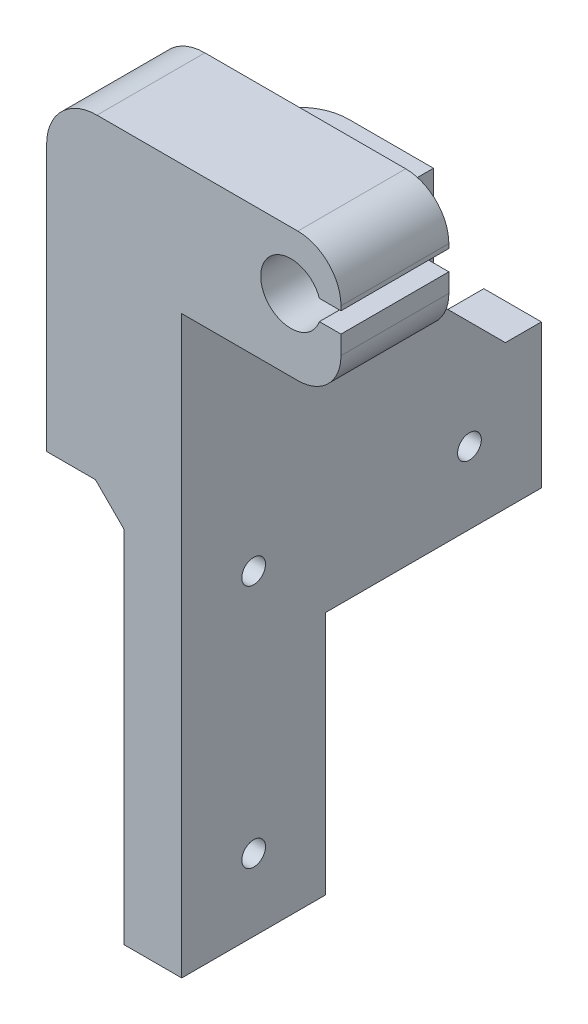
from build123d import *

# Parameters (mm, degrees)
EXTRUDE_1_DEPTH     = 15
SKETCH_4_W          = 18.78
SKETCH_4_H          = 26
EXTRUDE_4_DEPTH     = 20
SKETCH_5_W          = 8
SKETCH_5_H          = 54
EXTRUDE_5_DEPTH     = 5
SKETCH_6_R          = 4.2
CUT_EXTRUDE_1_DEPTH = 15
CHAMFER_1_SIZE      = 4
FILLET_3_R          = 7
FILLET_4_R          = 7
SKETCH_9_W          = 8
SKETCH_9_H          = 20
EXTRUDE_6_DEPTH     = 30
SKETCH_10_R         = 1.65
CUT_EXTRUDE_4_DEPTH = 30
CHAMFER_2_SIZE      = 10
SKETCH_11_W         = 3
SKETCH_11_H         = 6.600571545
SKETCH_11_H_2       = 8.600571545
EXTRUDE_7_DEPTH     = 15
FILLET_5_R          = 6
SKETCH_8_R          = 1.6
CUT_EXTRUDE_3_DEPTH = 93
FILLET_6_R          = 6


with BuildPart() as part:
    # 草图1 → 凸台-拉伸1 (new body)
    with BuildSketch(Plane.XY):
        Polygon((8, 26), (27.14, 26), (27.14, 44), (-10.78, 44), (-10.78, 0), (0, 0), (0, -54), (8, -54), align=None)
    extrude(amount=EXTRUDE_1_DEPTH)

    # 草图4 → 凸台-拉伸4 (add)
    with BuildSketch(Plane(origin=(0, 0, 0), x_dir=(-1, 0, 0), z_dir=(0, 0, -1))):
        with Locations((1.39, 13)):
            Rectangle(SKETCH_4_W, SKETCH_4_H)
    extrude(amount=EXTRUDE_4_DEPTH)

    # 草图5 → 凸台-拉伸5 (add)
    with BuildSketch(Plane(origin=(0, 0, 0), x_dir=(-1, 0, 0), z_dir=(0, 0, -1))):
        with Locations((-4, -27)):
            Rectangle(SKETCH_5_W, SKETCH_5_H)
    extrude(amount=EXTRUDE_5_DEPTH)

    # 草图6 → 切除-拉伸1 (cut)
    with BuildSketch(Plane(origin=(0, 0, 0), x_dir=(-1, 0, 0), z_dir=(0, 0, -1))):
        with Locations((-23.18, 36)):
            Circle(SKETCH_6_R)
    extrude(amount=-CUT_EXTRUDE_1_DEPTH, mode=Mode.SUBTRACT)

    # 倒角1
    chamfer_1_edges = [part.edges().sort_by_distance(p)[0] for p in [
        (0, 0, 5),
    ]]
    chamfer(chamfer_1_edges, length=CHAMFER_1_SIZE)

    # 圆角3
    fillet_3_edges = [part.edges().sort_by_distance(p)[0] for p in [
        (-10.78, 44, 7.5),
    ]]
    fillet(fillet_3_edges, radius=FILLET_3_R)

    # 圆角4
    fillet_4_edges = [part.edges().sort_by_distance(p)[0] for p in [
        (-10.78, 13, -20),
    ]]
    fillet(fillet_4_edges, radius=FILLET_4_R)

    # 草图9 → 凸台-拉伸6 (add)
    with BuildSketch(Plane(origin=(0, 0, -5), x_dir=(-1, 0, 0), z_dir=(0, 0, -1))):
        with Locations((-4, -10)):
            Rectangle(SKETCH_9_W, SKETCH_9_H)
    extrude(amount=EXTRUDE_6_DEPTH)

    # 草图10 → 切除-拉伸4 (cut)
    with BuildSketch(Plane.ZY):
        with Locations((-25, -10)):
            Circle(SKETCH_10_R)
        with Locations((5, -10)):
            Circle(SKETCH_10_R)
        with Locations((5, -44)):
            Circle(SKETCH_10_R)
    extrude(amount=-CUT_EXTRUDE_4_DEPTH, mode=Mode.SUBTRACT)

    # 倒角2
    chamfer_2_edges = [part.edges().sort_by_distance(p)[0] for p in [
        (4, 0, -20),
    ]]
    chamfer(chamfer_2_edges, length=CHAMFER_2_SIZE)

    # 草图11 → 凸台-拉伸7 (add)
    with BuildSketch(Plane.XY.offset(15)):
        with Locations((28.64, 40.699714227)):
            Rectangle(SKETCH_11_W, SKETCH_11_H)
        with Locations((28.64, 30.300285773)):
            Rectangle(SKETCH_11_W, SKETCH_11_H_2)
    extrude(amount=-EXTRUDE_7_DEPTH)

    # 圆角5
    fillet_5_edges = [part.edges().sort_by_distance(p)[0] for p in [
        (30.14, 44, 7.5),
    ]]
    fillet(fillet_5_edges, radius=FILLET_5_R)

    # 草图8 → 切除-拉伸3 (cut)
    with BuildSketch(Plane(origin=(0, 26, 0), x_dir=(1, 0, 0), z_dir=(0, 1, 0))):
        with Locations((1.22, 10.05)):
            Circle(SKETCH_8_R)
    extrude(amount=-CUT_EXTRUDE_3_DEPTH, mode=Mode.SUBTRACT)

    # 圆角6
    fillet_6_edges = [part.edges().sort_by_distance(p)[0] for p in [
        (30.14, 26, 7.5),
    ]]
    fillet(fillet_6_edges, radius=FILLET_6_R)


solid = part.part
